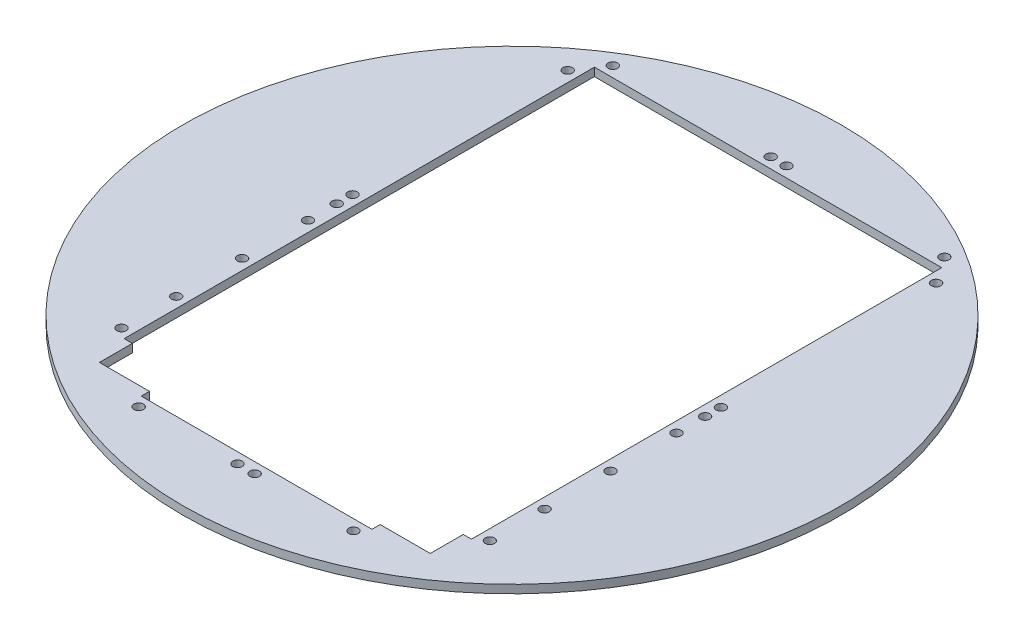
from build123d import *

# Parameters (mm, degrees)
SKETCH1_R           = 127
BOSS_EXTRUDE1_DEPTH = 3.175
SKETCH2_W           = 127
SKETCH2_H           = 190.5
CUT_EXTRUDE1_DEPTH  = 3.175
SKETCH3_W           = 114.3
SKETCH3_H           = 32.385
BOSS_EXTRUDE2_DEPTH = 3.175
SKETCH4_W           = 101.6
SKETCH4_H           = 6.35
CUT_EXTRUDE2_DEPTH  = 3.175
SKETCH5_W           = 101.6
SKETCH5_H           = 3.175
BOSS_EXTRUDE5_DEPTH = 3.175
SKETCH6_W           = 114.3
SKETCH6_H           = 32.385
CUT_EXTRUDE3_DEPTH  = 4.175
SKETCH7_R           = 1.8288
CUT_EXTRUDE4_DEPTH  = 4.175
SKETCH8_W           = 6.35
SKETCH8_H           = 3.175
BOSS_EXTRUDE6_DEPTH = 3.175
SKETCH9_R           = 1.8288
CUT_EXTRUDE5_DEPTH  = 3.175
SKETCH10_R          = 1.8288
BOSS_EXTRUDE7_DEPTH = 3.175
CUT_EXTRUDE6_DEPTH  = 4.175
SKETCH13_W          = 3.175
SKETCH13_H          = 178.054
CUT_EXTRUDE8_DEPTH  = 4.175
SKETCH14_R          = 1.8288
CUT_EXTRUDE9_DEPTH  = 4.175
SKETCH15_W          = 133.858
SKETCH15_H          = 3.175
CUT_EXTRUDE10_DEPTH = 4.175
SKETCH16_R          = 1.8288
CUT_EXTRUDE11_DEPTH = 4.175
SKETCH17_R          = 1.8288
CUT_EXTRUDE12_DEPTH = 4.175


with BuildPart() as part:
    # Sketch1 → Boss-Extrude1 (new body)
    with BuildSketch(Plane(origin=(0, 0, 0), x_dir=(1, 0, 0), z_dir=(0, 1, 0))):
        Circle(SKETCH1_R)
    extrude(amount=BOSS_EXTRUDE1_DEPTH)

    # Sketch2 → Cut-Extrude1 (cut)
    with BuildSketch(Plane(origin=(0, 3.175, 0), x_dir=(1, 0, 0), z_dir=(0, 1, 0))):
        Rectangle(SKETCH2_W, SKETCH2_H)
    extrude(amount=-CUT_EXTRUDE1_DEPTH, mode=Mode.SUBTRACT)

    # Sketch3 → Boss-Extrude2 (add)
    with BuildSketch(Plane(origin=(0, 3.175, 0), x_dir=(1, 0, 0), z_dir=(0, 1, 0))):
        with Locations((0, -79.0575)):
            Rectangle(SKETCH3_W, SKETCH3_H)
    extrude(amount=-BOSS_EXTRUDE2_DEPTH)

    # Sketch4 → Cut-Extrude2 (cut)
    with BuildSketch(Plane.XZ):
        with Locations((0, 95.25)):
            Rectangle(SKETCH4_W, SKETCH4_H)
    extrude(amount=-CUT_EXTRUDE2_DEPTH, mode=Mode.SUBTRACT)

    # Sketch5 → Boss-Extrude5 (add, through all)
    with BuildSketch(Plane.XZ):
        with Locations((0, 93.6625)):
            Rectangle(SKETCH5_W, SKETCH5_H)
    extrude(amount=-BOSS_EXTRUDE5_DEPTH)

    # Sketch6 → Cut-Extrude3 (cut, through all)
    with BuildSketch(Plane.XZ):
        with Locations((0, 79.0575)):
            Rectangle(SKETCH6_W, SKETCH6_H)
    extrude(amount=-CUT_EXTRUDE3_DEPTH, mode=Mode.SUBTRACT)

    # Sketch7 → Cut-Extrude4 (cut, through all)
    with BuildSketch(Plane.XZ):
        with Locations((-47.752, 102.489)):
            Circle(SKETCH7_R)
        with Locations((-3.302, 102.489)):
            Circle(SKETCH7_R)
        with Locations((3.302, 102.489)):
            Circle(SKETCH7_R)
        with Locations((47.752, 102.489)):
            Circle(SKETCH7_R)
    extrude(amount=-CUT_EXTRUDE4_DEPTH, mode=Mode.SUBTRACT)

    # Sketch8 → Boss-Extrude6 (add)
    with BuildSketch(Plane.XZ):
        with Locations((-47.625, 96.8375)):
            Rectangle(SKETCH8_W, SKETCH8_H)
        with Locations((47.625, 96.8375)):
            Rectangle(SKETCH8_W, SKETCH8_H)
    extrude(amount=-BOSS_EXTRUDE6_DEPTH)

    # Sketch9 → Cut-Extrude5 (cut)
    with BuildSketch(Plane.XZ):
        with Locations((-41.402, 102.489)):
            Circle(SKETCH9_R)
        with Locations((41.402, 102.489)):
            Circle(SKETCH9_R)
    extrude(amount=-CUT_EXTRUDE5_DEPTH, mode=Mode.SUBTRACT)

    # Sketch10 → Boss-Extrude7 (add)
    with BuildSketch(Plane.XZ):
        with Locations((-47.752, 102.489)):
            Circle(SKETCH10_R)
        with Locations((47.752, 102.489)):
            Circle(SKETCH10_R)
    extrude(amount=-BOSS_EXTRUDE7_DEPTH)

    # Sketch11 → Cut-Extrude6 (cut, through all)
    with BuildSketch(Plane.XZ):
        Polygon((-63.754, 95.25), (-63.5, 95.25), (-63.5, -95.25), (63.5, -95.25), (63.5, 95.25), (63.754, 95.25), (63.754, -95.504), (-63.754, -95.504), align=None)
    extrude(amount=-CUT_EXTRUDE6_DEPTH, mode=Mode.SUBTRACT)

    # Sketch13 → Cut-Extrude8 (cut, through all)
    with BuildSketch(Plane.XZ):
        with Locations((-65.3415, -6.477)):
            Rectangle(SKETCH13_W, SKETCH13_H)
        with Locations((65.3415, -6.477)):
            Rectangle(SKETCH13_W, SKETCH13_H)
    extrude(amount=-CUT_EXTRUDE8_DEPTH, mode=Mode.SUBTRACT)

    # Sketch14 → Cut-Extrude9 (cut, through all)
    with BuildSketch(Plane.XZ):
        with Locations((-70.993, 79.502)):
            Circle(SKETCH14_R)
        with Locations((-70.993, -92.456)):
            Circle(SKETCH14_R)
        with Locations((-70.993, -3.429)):
            Circle(SKETCH14_R)
        with Locations((-70.993, -9.525)):
            Circle(SKETCH14_R)
        with Locations((70.993, -92.456)):
            Circle(SKETCH14_R)
        with Locations((70.993, -9.525)):
            Circle(SKETCH14_R)
        with Locations((70.993, -3.429)):
            Circle(SKETCH14_R)
        with Locations((70.993, 79.502)):
            Circle(SKETCH14_R)
    extrude(amount=-CUT_EXTRUDE9_DEPTH, mode=Mode.SUBTRACT)

    # Sketch15 → Cut-Extrude10 (cut, through all)
    with BuildSketch(Plane.XZ):
        with Locations((0, -97.0915)):
            Rectangle(SKETCH15_W, SKETCH15_H)
    extrude(amount=-CUT_EXTRUDE10_DEPTH, mode=Mode.SUBTRACT)

    # Sketch16 → Cut-Extrude11 (cut, through all)
    with BuildSketch(Plane.XZ):
        with Locations((-63.881, -102.743)):
            Circle(SKETCH16_R)
        with Locations((-3.048, -102.743)):
            Circle(SKETCH16_R)
        with Locations((3.048, -102.743)):
            Circle(SKETCH16_R)
        with Locations((63.881, -102.743)):
            Circle(SKETCH16_R)
    extrude(amount=-CUT_EXTRUDE11_DEPTH, mode=Mode.SUBTRACT)

    # Sketch17 → Cut-Extrude12 (cut, through all)
    with BuildSketch(Plane.XZ):
        with Locations((-70.993, 7.62)):
            Circle(SKETCH17_R)
        with Locations((-70.993, 58.42)):
            Circle(SKETCH17_R)
        with Locations((-70.993, 33.02)):
            Circle(SKETCH17_R)
        with Locations((70.993, 58.42)):
            Circle(SKETCH17_R)
        with Locations((70.993, 7.62)):
            Circle(SKETCH17_R)
        with Locations((70.993, 33.02)):
            Circle(SKETCH17_R)
    extrude(amount=-CUT_EXTRUDE12_DEPTH, mode=Mode.SUBTRACT)


solid = part.part
